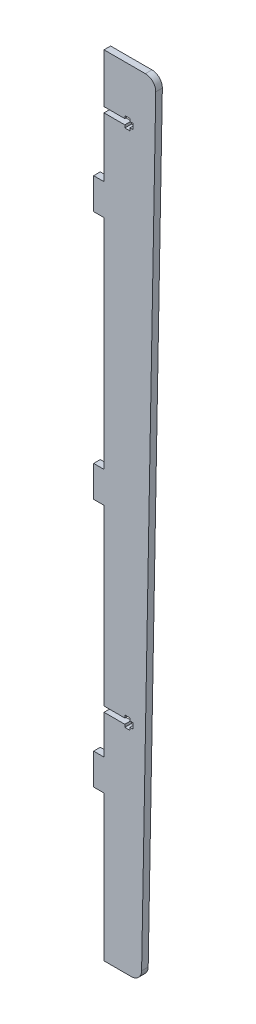
from build123d import *

# Parameters (mm, degrees)
BOSS_EXTRUDE1_DEPTH             = 1.5875
BOSS_EXTRUDE2_REACH             = 382.825
SKETCH1_4_W                     = 5
SKETCH1_4_H                     = 15
BOSS_EXTRUDE2_DIRECTION_2_REACH = 382.825
SKETCH1_5_W                     = 2.5
SKETCH1_5_H                     = 5.2
SKETCH1_5_W_2                   = 14
SKETCH1_5_H_2                   = 2.6
CUT_EXTRUDE2_DEPTH              = 381.824789314
LPATTERN1_COUNT                 = 3
LPATTERN1_PITCH                 = 120
LPATTERN3_COUNT                 = 2
LPATTERN3_PITCH                 = 250
FILLET1_R                       = 5


with BuildPart() as part:
    # Sketch1 → Boss-Extrude1 (new, symmetric)
    with BuildSketch(Plane.XY):
        Polygon((0, 0), (0, -380), (18, -380), (25, 0), align=None)
    extrude(amount=BOSS_EXTRUDE1_DEPTH, both=True)

    # Boss-Extrude2: up to this face of the body (flat: up to its plane)
    boss_extrude2_end = Plane(part.part.faces().sort_by_distance((10.84496124, -179.689922481, 1.5875))[0])
    # Sketch1_4 → Boss-Extrude2 (add, up to the picked face)
    with BuildSketch(Plane.XY, mode=Mode.PRIVATE) as boss_extrude2_sk1:
        with Locations((-2.5, -62.5)):
            Rectangle(SKETCH1_4_W, SKETCH1_4_H)
    boss_extrude2_tool1 = split(extrude(boss_extrude2_sk1.sketch, amount=BOSS_EXTRUDE2_REACH, mode=Mode.PRIVATE), bisect_by=boss_extrude2_end, keep=Keep.BOTH, mode=Mode.PRIVATE)
    boss_extrude2 = boss_extrude2_tool1.solids().sort_by(Axis((-2.5, -62.5, 0), (0, 0, 1)))[0]
    add(boss_extrude2)

    # Boss-Extrude2 direction 2: up to this face of the body (flat: up to its plane)
    boss_extrude2_direction_2_end = Plane(part.part.faces().sort_by_distance((10.84496124, -179.689922481, -1.5875))[0])
    # Sketch1_4 → Boss-Extrude2 direction 2 (add, up to the picked face)
    with BuildSketch(Plane.XY, mode=Mode.PRIVATE) as boss_extrude2_direction_2_sk1:
        with Locations((-2.5, -62.5)):
            Rectangle(SKETCH1_4_W, SKETCH1_4_H)
    boss_extrude2_direction_2_tool1 = split(extrude(boss_extrude2_direction_2_sk1.sketch, amount=-BOSS_EXTRUDE2_DIRECTION_2_REACH, mode=Mode.PRIVATE), bisect_by=boss_extrude2_direction_2_end, keep=Keep.BOTH, mode=Mode.PRIVATE)
    boss_extrude2_direction_2 = boss_extrude2_direction_2_tool1.solids().sort_by(Axis((-2.5, -62.5, 0), (0, 0, -1)))[0]
    add(boss_extrude2_direction_2)

    # Sketch1_5 → Cut-Extrude2 (cut, symmetric)
    with BuildSketch(Plane.XY):
        with Locations((11.25, -25)):
            Rectangle(SKETCH1_5_W, SKETCH1_5_H)
        with Locations((7, -25)):
            Rectangle(SKETCH1_5_W_2, SKETCH1_5_H_2)
    cut_extrude2 = extrude(amount=CUT_EXTRUDE2_DEPTH, both=True, mode=Mode.SUBTRACT)

    # LPattern1: Boss-Extrude2, Boss-Extrude2 direction 2 ×3
    with Locations(*[(0, -i * LPATTERN1_PITCH, 0) for i in range(1, LPATTERN1_COUNT)]):
        add(boss_extrude2)
        add(boss_extrude2_direction_2)

    # LPattern3: Cut-Extrude2 ×2
    with Locations(*[(0, -i * LPATTERN3_PITCH, 0) for i in range(1, LPATTERN3_COUNT)]):
        add(cut_extrude2, mode=Mode.SUBTRACT)

    # Fillet1
    fillet1_edges = [part.edges().sort_by_distance(p)[0] for p in [
        (18, -380, 0),
        (25, 0, 0),
    ]]
    fillet(fillet1_edges, radius=FILLET1_R)


solid = part.part
